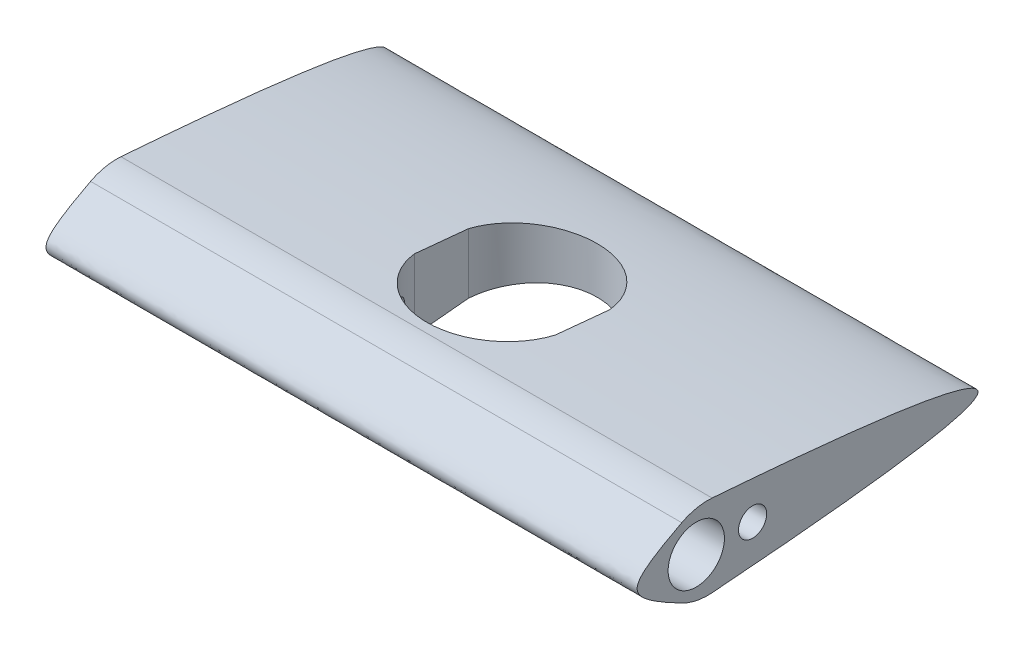
from build123d import *

# Parameters (mm, degrees)
SKETCH1_R               = 5
SKETCH1_R_2             = 2.5
BOSS_EXTRUDE1_DEPTH     = 105
FILLET1_R               = 10
CUT_EXTRUDE1_DEPTH      = 117.542660484
CUT_EXTRUDE1_DEPTH_BACK = 117.542660484


with BuildPart() as part:
    # Sketch1 → Boss-Extrude1 (new body)
    with BuildSketch(Plane(origin=(0, 0, 0), x_dir=(0, 0, -1), z_dir=(1, 0, 0))):
        with BuildLine():
            add(Edge.make_bspline(
                [(3.73e-07, 7.5), (-15, 0), (-3.73e-07, -7.5)],
                knots=[0, 0, 0, 1, 1, 1], degree=2, weights=[1, 2.333333333, 1]))
            add(Edge.make_bspline(
                [(3.73e-07, 7.5), (100, 0), (-3.73e-07, -7.5)],
                knots=[0, 0, 0, 1, 1, 1], degree=2, weights=[1, 1.001467765, 1]))
        make_face()
        Circle(SKETCH1_R, mode=Mode.SUBTRACT)
        with Locations((10, 0)):
            Circle(SKETCH1_R_2, mode=Mode.SUBTRACT)
    extrude(amount=BOSS_EXTRUDE1_DEPTH)

    # Fillet1
    fillet1_edges = [part.edges().sort_by_distance(p)[0] for p in [
        (52.5, 7.5, -3.73e-07),
        (52.5, -7.5, 3.73e-07),
    ]]
    fillet(fillet1_edges, radius=FILLET1_R)

    # Sketch2 → Cut-Extrude1 (cut, two sides)
    with BuildSketch(Plane(origin=(0, 0, 0), x_dir=(1, 0, 0), z_dir=(0, 1, 0))) as cut_extrude1_sk:
        with BuildLine():
            ThreePointArc((65, 24.578179161), (52.5, 34.902500415), (40, 24.578179161))
            Line((40, 24.578179161), (40, 19.76833361))
            Line((40, 19.76833361), (40, 14.958488059))
            ThreePointArc((40, 14.958488059), (52.5, 4.634166805), (65, 14.958488059))
            Line((65, 14.958488059), (65, 19.76833361))
            Line((65, 19.76833361), (65, 24.578179161))
        make_face()
    extrude(amount=CUT_EXTRUDE1_DEPTH, mode=Mode.SUBTRACT)
    extrude(cut_extrude1_sk.sketch, amount=-CUT_EXTRUDE1_DEPTH_BACK, mode=Mode.SUBTRACT)


solid = part.part
